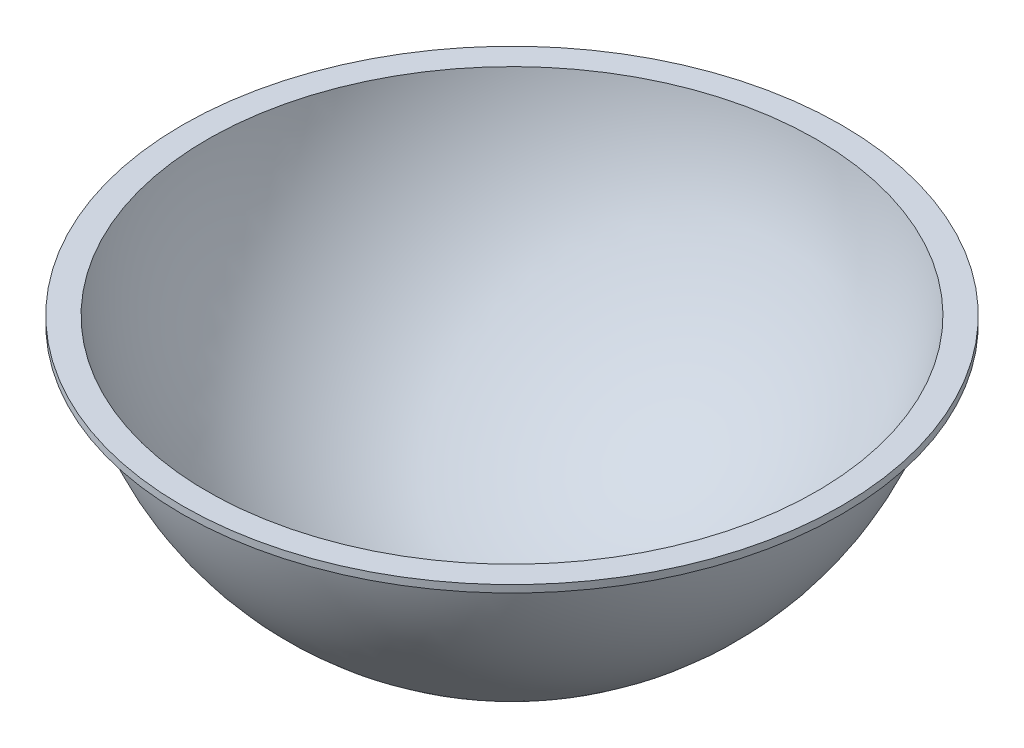
from build123d import *


with BuildPart() as part:
    # Croquis1 → Revolución2 (revolve)
    with BuildSketch(Plane(origin=(0, 0, 0), x_dir=(0, 0, -1), z_dir=(1, 0, 0))):
        with BuildLine():
            Line((107.95, 88.9), (114.504378868, 88.9))
            Line((114.504378868, 88.9), (114.504378868, 91.44))
            Line((114.504378868, 91.44), (105.837566582, 91.44))
            ThreePointArc((105.837566582, 91.44), (69.11005806, 27.713901897), (0, 2.54))
            Line((0, 2.54), (0, 0))
            ThreePointArc((0, 0), (69.922121857, 25.085637745), (107.95, 88.9))
        make_face()
    revolve(axis=Axis((0, 0, 0), (0, 1, 0)))


solid = part.part
